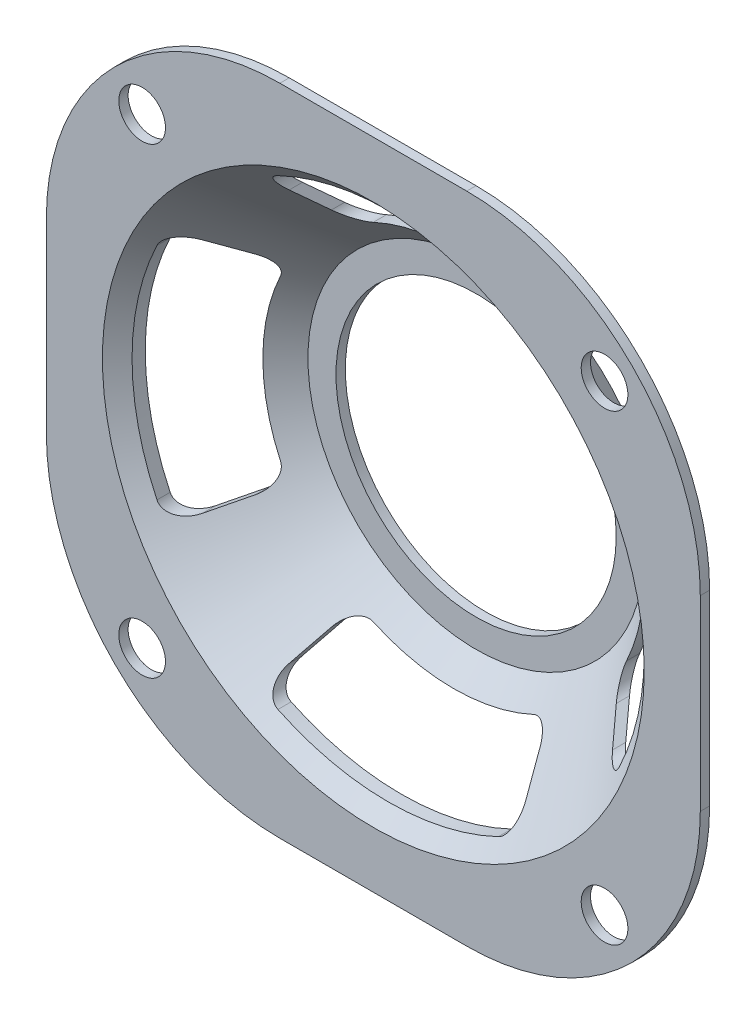
from build123d import *

# Parameters (mm, degrees)
EXTRUDE1_DEPTH     = 1
SKETCH6_R          = 30
CUT_EXTRUDE1_DEPTH = 50.507575178
SKETCH7_R          = 2.5
CUT_EXTRUDE3_DEPTH = 50.507575178
CUT_EXTRUDE4_DEPTH = 51.931326313
CIRPATTERN1_COUNT  = 4


with BuildPart() as part:
    # Sketch1 → Extrude1 (new body)
    with BuildSketch(Plane.XY):
        with BuildLine():
            Line((-10, -35), (10, -35))
            ThreePointArc((10, -35), (27.67766953, -27.67766953), (35, -10))
            Line((35, -10), (35, 10))
            ThreePointArc((35, 10), (27.67766953, 27.67766953), (10, 35))
            Line((10, 35), (-10, 35))
            ThreePointArc((-10, 35), (-27.67766953, 27.67766953), (-35, 10))
            Line((-35, 10), (-35, -10))
            ThreePointArc((-35, -10), (-27.67766953, -27.67766953), (-10, -35))
        make_face()
    extrude(amount=-EXTRUDE1_DEPTH)

    # Sketch6 → Cut-Extrude1 (cut, through all)
    with BuildSketch(Plane(origin=(0, 0, -1), x_dir=(-1, 0, 0), z_dir=(0, 0, -1))):
        Circle(SKETCH6_R)
    extrude(amount=-CUT_EXTRUDE1_DEPTH, mode=Mode.SUBTRACT)

    # Sketch7 → Cut-Extrude3 (cut, through all)
    with BuildSketch(Plane(origin=(0, 0, -1), x_dir=(-1, 0, 0), z_dir=(0, 0, -1))):
        with Locations((-24.748737342, 24.748737342)):
            Circle(SKETCH7_R)
        with Locations((24.748737342, 24.748737342)):
            Circle(SKETCH7_R)
        with Locations((24.748737342, -24.748737342)):
            Circle(SKETCH7_R)
        with Locations((-24.748737342, -24.748737342)):
            Circle(SKETCH7_R)
    extrude(amount=-CUT_EXTRUDE3_DEPTH, mode=Mode.SUBTRACT)

    # Sketch8 → Revolve-Thin1 (revolve)
    with BuildSketch(Plane(origin=(0, 0, 0), x_dir=(0, 0, -1), z_dir=(1, 0, 0))):
        Polygon((0, 30), (0, 29), (11, 18), (11, 15), (12, 15), (12, 18.414213562), (1, 29.414213562), (1, 30), align=None)
    revolve(axis=Axis((0, 0, 0), (0, 0, -1)))

    # Sketch9 → Cut-Extrude4 (cut, through all)
    with BuildSketch(Plane(origin=(0, 0, -12), x_dir=(-1, 0, 0), z_dir=(0, 0, -1))):
        with BuildLine():
            Line((11.162403075, 19.33384926), (12.66769761, 21.941095876))
            ThreePointArc((12.66769761, 21.941095876), (12.845616173, 23.534406087), (11.796239776, 24.74647111))
            ThreePointArc((11.796239776, 24.74647111), (0, 27.414213562), (-11.796239776, 24.74647111))
            ThreePointArc((-11.796239776, 24.74647111), (-12.845616173, 23.534406087), (-12.66769761, 21.941095876))
            Line((-12.66769761, 21.941095876), (-11.162403075, 19.33384926))
            ThreePointArc((-11.162403075, 19.33384926), (-10.033748667, 18.4270423), (-8.588890465, 18.519478285))
            ThreePointArc((-8.588890465, 18.519478285), (0, 20.414213562), (8.588890465, 18.519478285))
            ThreePointArc((8.588890465, 18.519478285), (10.033748667, 18.4270423), (11.162403075, 19.33384926))
        make_face()
    cut_extrude4 = extrude(amount=-CUT_EXTRUDE4_DEPTH, mode=Mode.SUBTRACT)

    # CirPattern1: Cut-Extrude4 ×4 about axis
    cirpattern1_axis = Axis((0, 0, 0), (0, 0, -1))
    for i in range(1, CIRPATTERN1_COUNT):
        add(cut_extrude4.rotate(cirpattern1_axis, i * 360 / CIRPATTERN1_COUNT), mode=Mode.SUBTRACT)


solid = part.part
